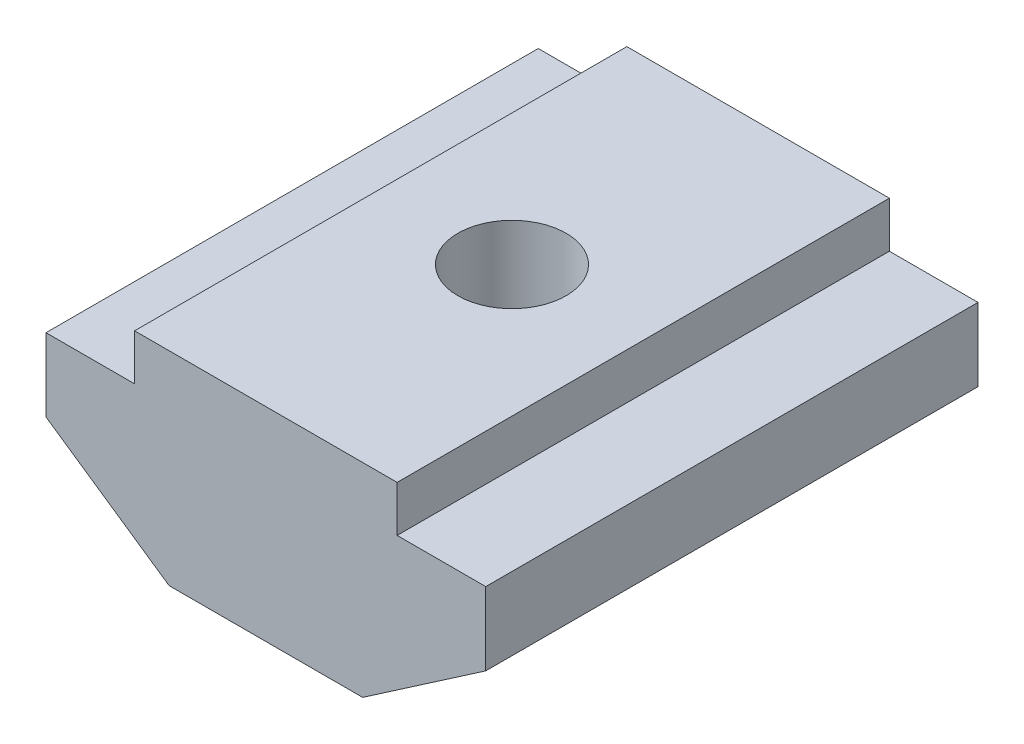
from build123d import *

# Parameters (mm, degrees)
EXTRUDE_1_DEPTH   = 7.5
HOLE_WIZARD_M41_D = 3.3


with BuildPart() as part:
    # Эскиз1 → Бобышка-Вытянуть1 (new body, symmetric)
    with BuildSketch(Plane.XY):
        Polygon((4, 0), (-4, 0), (-4, -1.4), (-6.7, -1.4), (-6.7, -3.625153657), (-2.948598936, -6.2), (2.948598936, -6.2), (6.7, -3.625153657), (6.7, -1.4), (4, -1.4), align=None)
    extrude(amount=EXTRUDE_1_DEPTH, both=True)

    # Отверстие обработанное метчиком M41 (through all)
    with Locations(Plane.ZX):
        with Locations((0, 0)):
            Hole(HOLE_WIZARD_M41_D / 2)


solid = part.part
